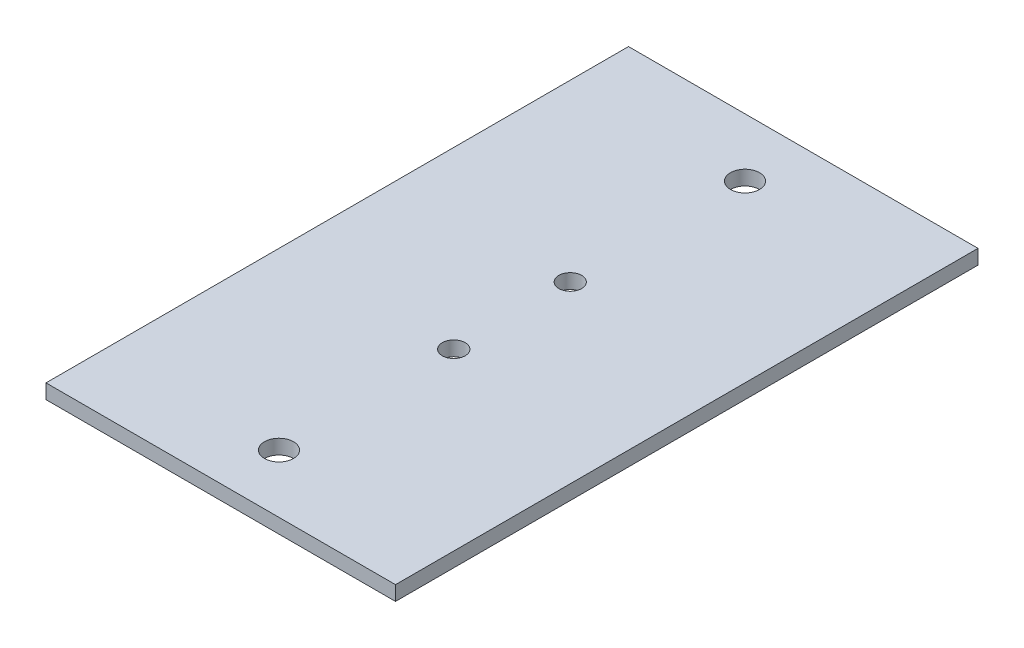
from build123d import *

# Parameters (mm, degrees)
SKETCH1_W           = 76.2
SKETCH1_H           = 3.175
EXTRUDE_THIN1_DEPTH = 127
SKETCH2_R           = 3.175
SKETCH2_R_2         = 2.4892
CUT_EXTRUDE1_DEPTH  = 4.175


with BuildPart() as part:
    # Sketch1 → Extrude-Thin1 (new body)
    with BuildSketch(Plane.XY):
        with Locations((38.1, -1.5875)):
            Rectangle(SKETCH1_W, SKETCH1_H)
    extrude(amount=EXTRUDE_THIN1_DEPTH)

    # Sketch2 → Cut-Extrude1 (cut, through all)
    with BuildSketch(Plane(origin=(0, 0, 0), x_dir=(1, 0, 0), z_dir=(0, 1, 0))):
        with Locations((38.1, -12.7)):
            Circle(SKETCH2_R)
        with Locations((38.1, -50.8)):
            Circle(SKETCH2_R_2)
        with Locations((38.1, -76.2)):
            Circle(SKETCH2_R_2)
        with Locations((38.1, -114.3)):
            Circle(SKETCH2_R)
    extrude(amount=-CUT_EXTRUDE1_DEPTH, mode=Mode.SUBTRACT)


solid = part.part
